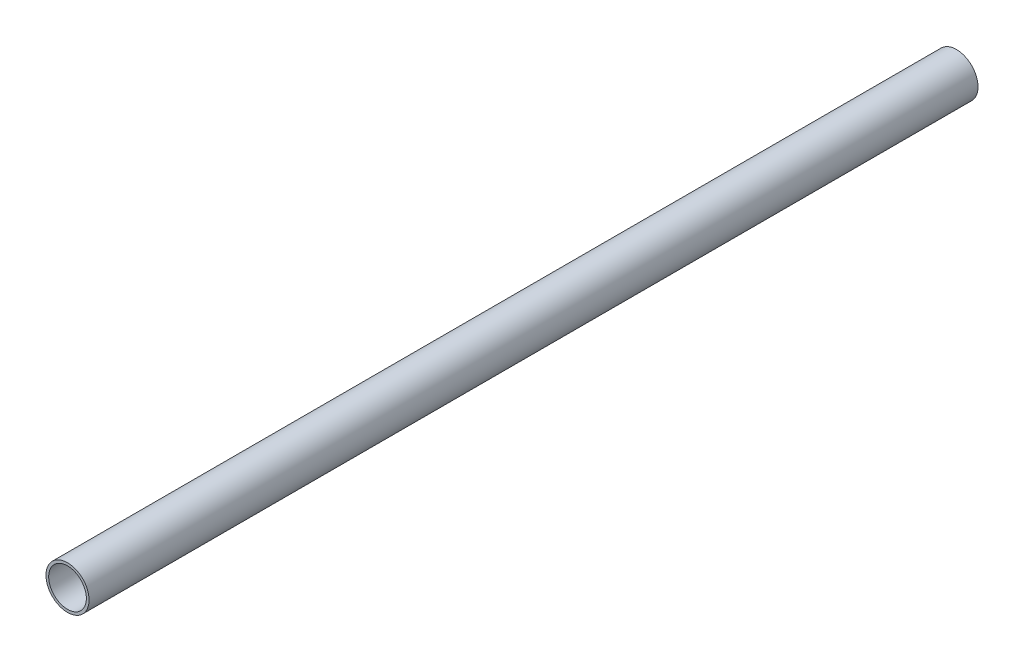
from build123d import *

# Parameters (mm, degrees)
EXTRUDE_2_DEPTH      = 165
EXTRUDE_2_DEPTH_BACK = 165
SKETCH_1_R           = 8
SKETCH_1_R_2         = 7


with BuildPart() as part:
    # Эскиз1 → Бобышка-Вытянуть2 (new, two sides: drawn at the far end of the back side and taken through both)
    with BuildSketch(Plane.XY.offset(-EXTRUDE_2_DEPTH_BACK)):
        Circle(SKETCH_1_R)
        Circle(SKETCH_1_R_2, mode=Mode.SUBTRACT)
    extrude(amount=EXTRUDE_2_DEPTH + EXTRUDE_2_DEPTH_BACK)


solid = part.part
